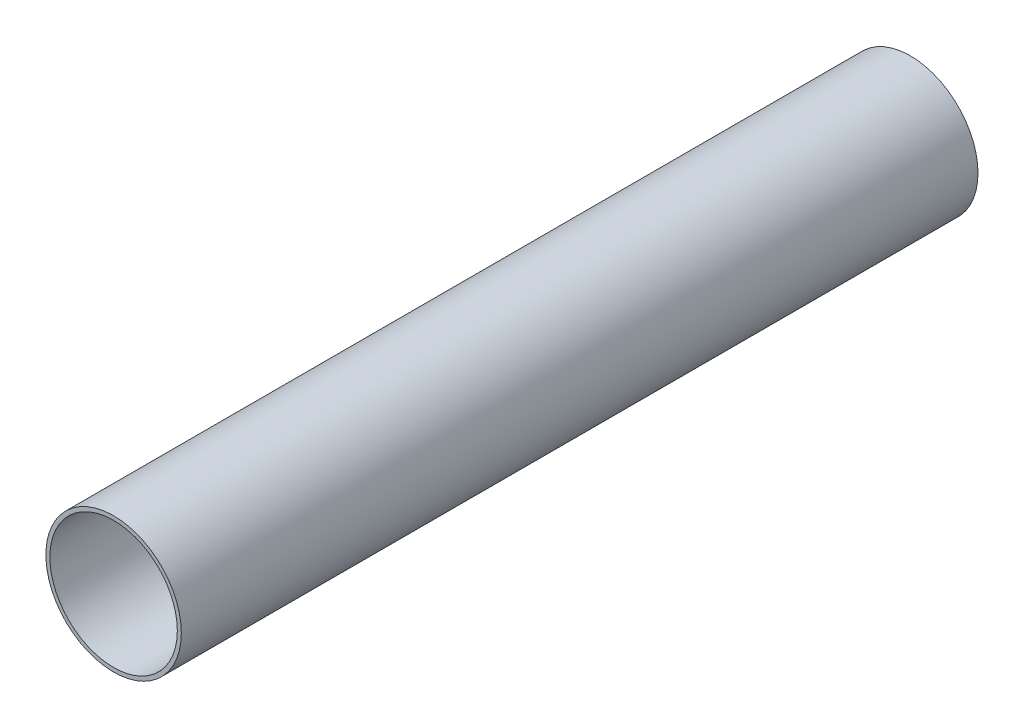
from build123d import *

# Parameters (mm, degrees)
SKETCH2_R           = 17
SKETCH2_R_2         = 16
BOSS_EXTRUDE2_DEPTH = 200


with BuildPart() as part:
    # Sketch2 → Boss-Extrude2 (new body)
    with BuildSketch(Plane.XY):
        Circle(SKETCH2_R)
        Circle(SKETCH2_R_2, mode=Mode.SUBTRACT)
    extrude(amount=BOSS_EXTRUDE2_DEPTH)


solid = part.part
